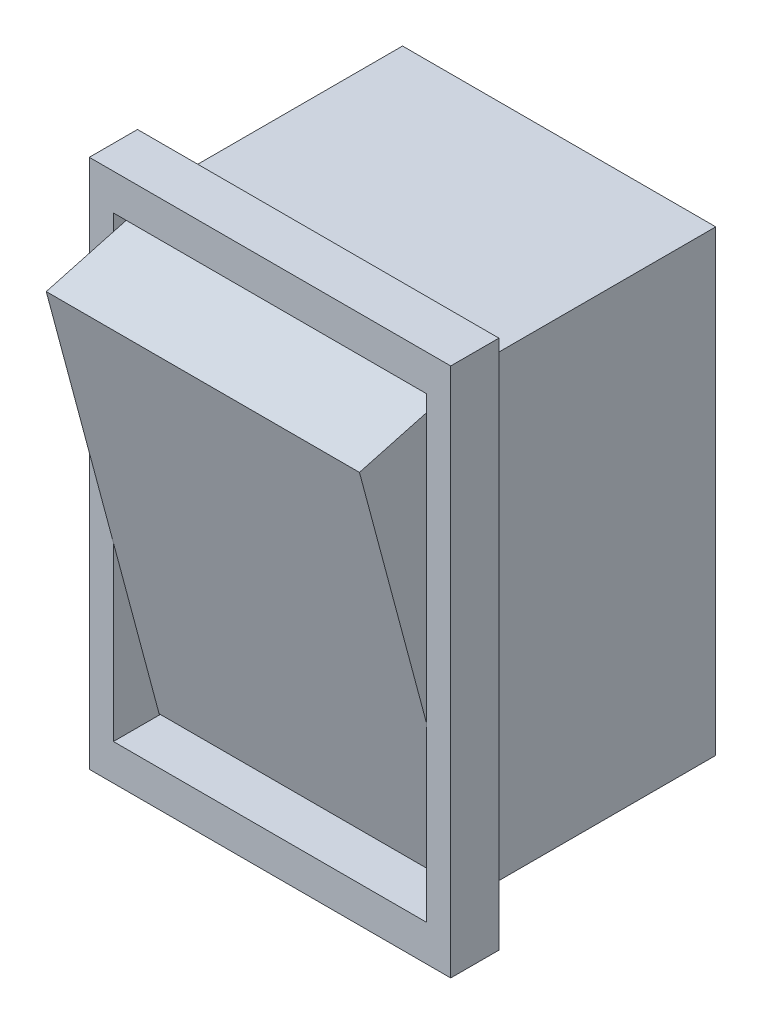
from build123d import *

# Parameters (mm, degrees)
SKETCH1_W            = 13
SKETCH1_H            = 19
BOSS_EXTRUDE1_DEPTH  = 10
SKETCH2_W            = 15
SKETCH2_H            = 22
SKETCH2_W_2          = 13
SKETCH2_H_2          = 19
BOSS_EXTRUDE2_DEPTH  = 2
BOSS_EXTRUDE11_DEPTH = 13


with BuildPart() as part:
    # Sketch1 → Boss-Extrude1 (new body)
    with BuildSketch(Plane.XY):
        Rectangle(SKETCH1_W, SKETCH1_H)
    extrude(amount=BOSS_EXTRUDE1_DEPTH)


with BuildPart() as body_2:
    # Sketch2 → Boss-Extrude2 (new body)
    with BuildSketch(Plane.XY.offset(10)):
        Rectangle(SKETCH2_W, SKETCH2_H)
        Rectangle(SKETCH2_W_2, SKETCH2_H_2, mode=Mode.SUBTRACT)
    extrude(amount=BOSS_EXTRUDE2_DEPTH)

    # Sketch3 → Boss-Extrude11 (add)
    with BuildSketch(Plane(origin=(-6.5, 0, 0), x_dir=(0, 0, -1), z_dir=(1, 0, 0))):
        Polygon((-10.102824212, 9.337921341), (-14.787277325, 8.067403047), (-10.102824212, -9.450012288), align=None)
    extrude(amount=BOSS_EXTRUDE11_DEPTH)


solid = Compound([part.part, body_2.part])
